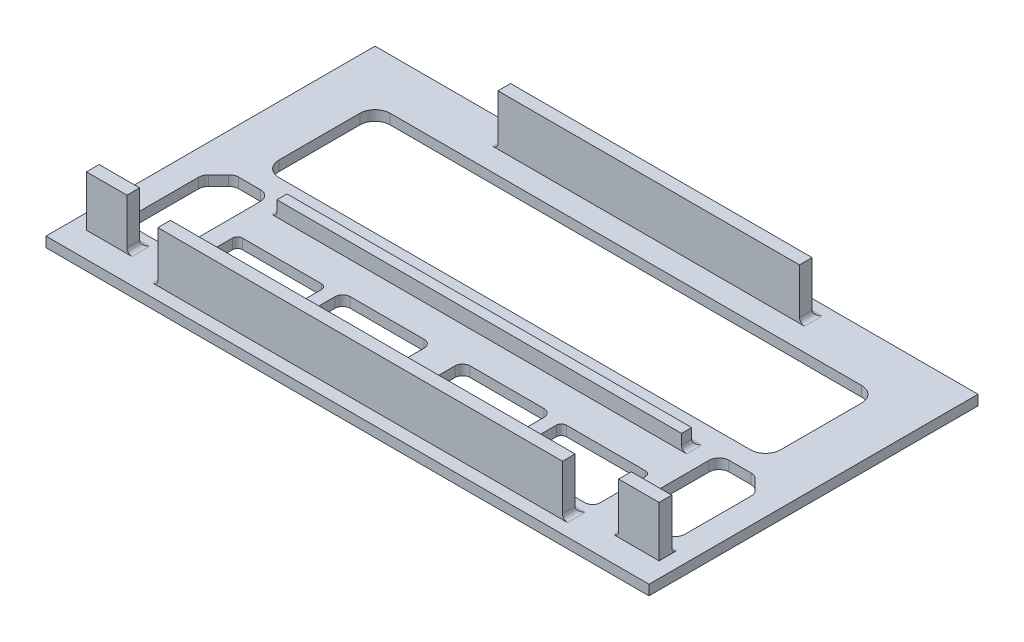
from build123d import *

# Parameters (mm, degrees)
SKETCH1_W           = 119.2
SKETCH1_H           = 65.04
BOSS_EXTRUDE1_DEPTH = 2
SKETCH2_W           = 59.6
SKETCH2_H           = 2.5
SKETCH2_W_2         = 80
SKETCH2_H_2         = 2
BOSS_EXTRUDE2_DEPTH = 10
FILLET1_R           = 1
SKETCH3_W           = 80
SKETCH3_H           = 2
CUT_EXTRUDE1_DEPTH  = 7
SKETCH4_W           = 80
SKETCH4_H           = 2.5
SKETCH4_W_2         = 8
BOSS_EXTRUDE3_DEPTH = 10
FILLET2_R           = 1
FILLET3_R           = 1
CUT_EXTRUDE2_DEPTH  = 10
CUT_EXTRUDE3_DEPTH  = 10


with BuildPart() as part:
    # Sketch1 → Boss-Extrude1 (new body)
    with BuildSketch(Plane(origin=(0, 0, 0), x_dir=(1, 0, 0), z_dir=(0, 1, 0))):
        Rectangle(SKETCH1_W, SKETCH1_H)
    extrude(amount=BOSS_EXTRUDE1_DEPTH)

    # Sketch2 → Boss-Extrude2 (add)
    with BuildSketch(Plane(origin=(0, 2, 0), x_dir=(1, 0, 0), z_dir=(0, 1, 0))):
        with Locations((0, 28.27)):
            Rectangle(SKETCH2_W, SKETCH2_H)
        with Locations((0, -5.48)):
            Rectangle(SKETCH2_W_2, SKETCH2_H_2)
    extrude(amount=BOSS_EXTRUDE2_DEPTH)

    # Fillet1
    fillet1_edges = [part.edges().sort_by_distance(p)[0] for p in [
        (-29.8, 2, -28.27),
        (29.8, 2, -28.27),
        (0, 2, -29.52),
        (-40, 2, 5.48),
        (40, 2, 5.48),
        (0, 2, 4.48),
    ]]
    fillet(fillet1_edges, radius=FILLET1_R)

    # Sketch3 → Cut-Extrude1 (cut)
    with BuildSketch(Plane(origin=(0, 12, 0), x_dir=(1, 0, 0), z_dir=(0, 1, 0))):
        with Locations((0, -5.48)):
            Rectangle(SKETCH3_W, SKETCH3_H)
        with Locations((0, -9.48)):
            Rectangle(SKETCH3_W, SKETCH3_H)
    extrude(amount=-CUT_EXTRUDE1_DEPTH, mode=Mode.SUBTRACT)

    # Sketch4 → Boss-Extrude3 (add)
    with BuildSketch(Plane(origin=(0, 2, 0), x_dir=(1, 0, 0), z_dir=(0, 1, 0))):
        with Locations((0, -28.77)):
            Rectangle(SKETCH4_W, SKETCH4_H)
        with Locations((52.6, -26.27)):
            Rectangle(SKETCH4_W_2, SKETCH4_H)
    boss_extrude3 = extrude(amount=BOSS_EXTRUDE3_DEPTH)

    # Fillet2
    fillet2_edges = [part.edges().sort_by_distance(p)[0] for p in [
        (-40, 2, 28.77),
        (48.6, 2, 26.27),
        (52.6, 2, 25.02),
        (40, 2, 28.77),
        (0, 2, 27.52),
    ]]
    fillet(fillet2_edges, radius=FILLET2_R)

    # Mirror1: Boss-Extrude3 across plane
    add(boss_extrude3.mirror(Plane.ZY))

    # Fillet3
    fillet3_edges = [part.edges().sort_by_distance(p)[0] for p in [
        (-52.6, 2, 25.02),
        (-48.6, 2, 26.27),
    ]]
    fillet(fillet3_edges, radius=FILLET3_R)

    # Sketch5 → Cut-Extrude2 (cut)
    with BuildSketch(Plane(origin=(0, 2, 0), x_dir=(1, 0, 0), z_dir=(0, 1, 0))):
        with BuildLine():
            Line((46.6, 22.52), (6.311514948, 22.52))
            Line((6.311514948, 22.52), (-46.6, 22.52))
            ThreePointArc((-46.6, 22.52), (-48.721320344, 21.641320344), (-49.6, 19.52))
            Line((-49.6, 19.52), (-49.6, 3.52))
            ThreePointArc((-49.6, 3.52), (-48.721320344, 1.398679656), (-46.6, 0.52))
            Line((-46.6, 0.52), (46.6, 0.52))
            ThreePointArc((46.6, 0.52), (48.721320344, 1.398679656), (49.6, 3.52))
            Line((49.6, 3.52), (49.6, 19.52))
            ThreePointArc((49.6, 19.52), (48.721320344, 21.641320344), (46.6, 22.52))
        make_face()
    extrude(amount=-CUT_EXTRUDE2_DEPTH, mode=Mode.SUBTRACT)

    # Sketch6 → Cut-Extrude3 (cut)
    with BuildSketch(Plane(origin=(0, 2, 0), x_dir=(1, 0, 0), z_dir=(0, 1, 0))):
        with BuildLine():
            Line((54.014213562, -5.94084617), (52.045315698, -3.971948306))
            ThreePointArc((52.045315698, -3.971948306), (51.396469, -3.538402803), (50.631102135, -3.386161868))
            Line((50.631102135, -3.386161868), (46.32782558, -3.386161868))
            ThreePointArc((46.32782558, -3.386161868), (44.913612017, -3.971948306), (44.32782558, -5.386161868))
            Line((44.32782558, -5.386161868), (44.32782558, -20.397912268))
            ThreePointArc((44.32782558, -20.397912268), (44.913612017, -21.812125831), (46.32782558, -22.397912268))
            Line((46.32782558, -22.397912268), (52.6, -22.397912268))
            ThreePointArc((52.6, -22.397912268), (54.014213562, -21.812125831), (54.6, -20.397912268))
            Line((54.6, -20.397912268), (54.6, -7.355059733))
            ThreePointArc((54.6, -7.355059733), (54.447759065, -6.589692868), (54.014213562, -5.94084617))
        make_face()
        with BuildLine():
            Line((39.82782558, -13.44932419), (24.210760832, -13.44932419))
            ThreePointArc((24.210760832, -13.44932419), (23.503654051, -13.742217409), (23.210760832, -14.44932419))
            Line((23.210760832, -14.44932419), (23.210760832, -23.393622011))
            ThreePointArc((23.210760832, -23.393622011), (23.650100661, -24.454282183), (24.710760832, -24.893622011))
            Line((24.710760832, -24.893622011), (39.32782558, -24.893622011))
            ThreePointArc((39.32782558, -24.893622011), (40.388485752, -24.454282183), (40.82782558, -23.393622011))
            Line((40.82782558, -23.393622011), (40.82782558, -14.44932419))
            ThreePointArc((40.82782558, -14.44932419), (40.534932361, -13.742217409), (39.82782558, -13.44932419))
        make_face()
        with BuildLine():
            Line((4.043952302, -24.893622011), (19.660852384, -24.893622011))
            ThreePointArc((19.660852384, -24.893622011), (20.367959165, -24.600728792), (20.660852384, -23.893622011))
            Line((20.660852384, -23.893622011), (20.660852384, -14.321364431))
            ThreePointArc((20.660852384, -14.321364431), (20.221512556, -13.260704259), (19.160852384, -12.821364431))
            Line((19.160852384, -12.821364431), (4.543952302, -12.821364431))
            ThreePointArc((4.543952302, -12.821364431), (3.48329213, -13.260704259), (3.043952302, -14.321364431))
            Line((3.043952302, -14.321364431), (3.043952302, -23.893622011))
            ThreePointArc((3.043952302, -23.893622011), (3.336845521, -24.600728792), (4.043952302, -24.893622011))
        make_face()
        with BuildLine():
            Line((-4.043952302, -24.893622011), (-19.660852384, -24.893622011))
            ThreePointArc((-19.660852384, -24.893622011), (-20.367959165, -24.600728792), (-20.660852384, -23.893622011))
            Line((-20.660852384, -23.893622011), (-20.660852384, -14.321364431))
            ThreePointArc((-20.660852384, -14.321364431), (-20.221512556, -13.260704259), (-19.160852384, -12.821364431))
            Line((-19.160852384, -12.821364431), (-4.543952302, -12.821364431))
            ThreePointArc((-4.543952302, -12.821364431), (-3.48329213, -13.260704259), (-3.043952302, -14.321364431))
            Line((-3.043952302, -14.321364431), (-3.043952302, -23.893622011))
            ThreePointArc((-3.043952302, -23.893622011), (-3.336845521, -24.600728792), (-4.043952302, -24.893622011))
        make_face()
        with BuildLine():
            Line((-39.32782558, -24.893622011), (-24.710760832, -24.893622011))
            ThreePointArc((-24.710760832, -24.893622011), (-23.650100661, -24.454282183), (-23.210760832, -23.393622011))
            Line((-23.210760832, -23.393622011), (-23.210760832, -14.44932419))
            ThreePointArc((-23.210760832, -14.44932419), (-23.503654051, -13.742217409), (-24.210760832, -13.44932419))
            Line((-24.210760832, -13.44932419), (-39.82782558, -13.44932419))
            ThreePointArc((-39.82782558, -13.44932419), (-40.534932361, -13.742217409), (-40.82782558, -14.44932419))
            Line((-40.82782558, -14.44932419), (-40.82782558, -23.393622011))
            ThreePointArc((-40.82782558, -23.393622011), (-40.388485752, -24.454282183), (-39.32782558, -24.893622011))
        make_face()
        with BuildLine():
            Line((-44.32782558, -5.386161868), (-44.32782558, -20.397912268))
            ThreePointArc((-44.32782558, -20.397912268), (-44.913612017, -21.812125831), (-46.32782558, -22.397912268))
            Line((-46.32782558, -22.397912268), (-52.6, -22.397912268))
            ThreePointArc((-52.6, -22.397912268), (-54.014213562, -21.812125831), (-54.6, -20.397912268))
            Line((-54.6, -20.397912268), (-54.6, -7.355059733))
            ThreePointArc((-54.6, -7.355059733), (-54.447759065, -6.589692868), (-54.014213562, -5.94084617))
            Line((-54.014213562, -5.94084617), (-52.045315698, -3.971948306))
            ThreePointArc((-52.045315698, -3.971948306), (-51.396469, -3.538402803), (-50.631102135, -3.386161868))
            Line((-50.631102135, -3.386161868), (-46.32782558, -3.386161868))
            ThreePointArc((-46.32782558, -3.386161868), (-44.913612017, -3.971948306), (-44.32782558, -5.386161868))
        make_face()
    extrude(amount=-CUT_EXTRUDE3_DEPTH, mode=Mode.SUBTRACT)


solid = part.part
